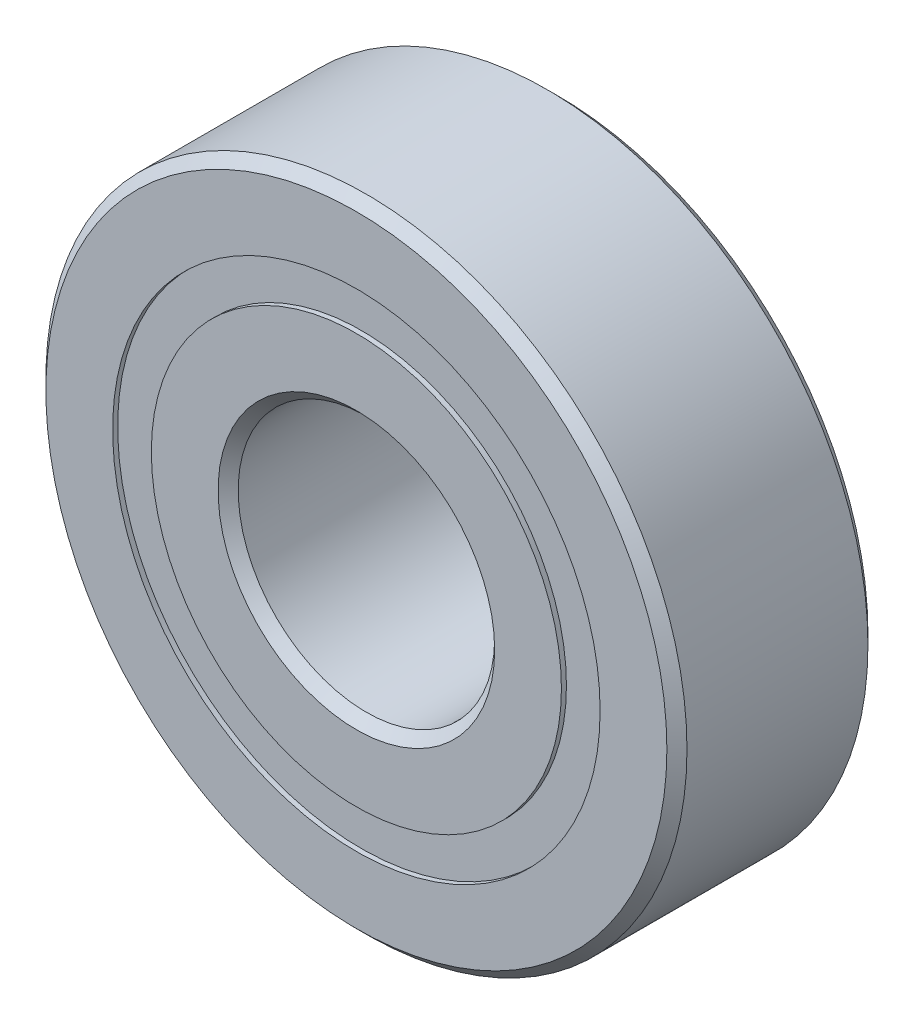
from build123d import *

# Parameters (mm, degrees)
CIRPATTERN1_COUNT = 10
SKETCH5_W         = 1.15919535
SKETCH5_H         = 0.957942858


with BuildPart() as part:
    # Sketch1 → Revolve1 (revolve)
    with BuildSketch(Plane(origin=(0, 0, 0), x_dir=(0, 0, -1), z_dir=(1, 0, 0))):
        with BuildLine():
            Line((2.24028, 7.9375), (-2.24028, 7.9375))
            Line((-2.24028, 7.9375), (-2.4892, 7.68858))
            Line((-2.4892, 7.68858), (-2.4892, 6.035221429))
            Line((-2.4892, 6.035221429), (-1.106311111, 6.035221429))
            ThreePointArc((-1.106311111, 6.035221429), (0, 6.76179465), (1.106311111, 6.035221429))
            Line((1.106311111, 6.035221429), (2.4892, 6.035221429))
            Line((2.4892, 6.035221429), (2.4892, 7.68858))
            Line((2.4892, 7.68858), (2.24028, 7.9375))
        make_face()
    revolve(axis=Axis((0, 0, 2.4892), (0, 0, -1)))


with BuildPart() as body_2:
    # Sketch3 → Revolve3 (revolve)
    with BuildSketch(Plane(origin=(0, 0, 0), x_dir=(0, 0, -1), z_dir=(1, 0, 0))):
        with BuildLine():
            Line((-2.4892, 5.077278571), (-1.106311111, 5.077278571))
            ThreePointArc((-1.106311111, 5.077278571), (0, 4.35070535), (1.106311111, 5.077278571))
            Line((1.106311111, 5.077278571), (2.4892, 5.077278571))
            Line((2.4892, 5.077278571), (2.4892, 3.42392))
            Line((2.4892, 3.42392), (2.24028, 3.175))
            Line((2.24028, 3.175), (-2.24028, 3.175))
            Line((-2.24028, 3.175), (-2.4892, 3.42392))
            Line((-2.4892, 3.42392), (-2.4892, 5.077278571))
        make_face()
    revolve(axis=Axis((0, 0, 2.4892), (0, 0, -1)))


with BuildPart() as body_3:
    # Sketch4 → Revolve4 (revolve)
    with BuildSketch(Plane(origin=(0, 0, 0), x_dir=(0, 0, -1), z_dir=(1, 0, 0))):
        with BuildLine():
            Line((-1.20554465, 5.55625), (1.20554465, 5.55625))
            ThreePointArc((1.20554465, 5.55625), (0, 6.76179465), (-1.20554465, 5.55625))
        make_face()
    revolve(axis=Axis((0, 5.55625, 1.20554465), (0, 0, -1)))


with BuildPart() as cirpattern1_1:
    # CirPattern1: pattern copy
    add(body_3.part.rotate(Axis((0, 0, -2.4892), (0, 0, 1)), 1 * 360 / CIRPATTERN1_COUNT))


with BuildPart() as cirpattern1_2:
    # CirPattern1: pattern copy
    add(body_3.part.rotate(Axis((0, 0, -2.4892), (0, 0, 1)), 2 * 360 / CIRPATTERN1_COUNT))


with BuildPart() as cirpattern1_3:
    # CirPattern1: pattern copy
    add(body_3.part.rotate(Axis((0, 0, -2.4892), (0, 0, 1)), 3 * 360 / CIRPATTERN1_COUNT))


with BuildPart() as cirpattern1_4:
    # CirPattern1: pattern copy
    add(body_3.part.rotate(Axis((0, 0, -2.4892), (0, 0, 1)), 4 * 360 / CIRPATTERN1_COUNT))


with BuildPart() as cirpattern1_5:
    # CirPattern1: pattern copy
    add(body_3.part.rotate(Axis((0, 0, -2.4892), (0, 0, 1)), 5 * 360 / CIRPATTERN1_COUNT))


with BuildPart() as cirpattern1_6:
    # CirPattern1: pattern copy
    add(body_3.part.rotate(Axis((0, 0, -2.4892), (0, 0, 1)), 6 * 360 / CIRPATTERN1_COUNT))


with BuildPart() as cirpattern1_7:
    # CirPattern1: pattern copy
    add(body_3.part.rotate(Axis((0, 0, -2.4892), (0, 0, 1)), 7 * 360 / CIRPATTERN1_COUNT))


with BuildPart() as cirpattern1_8:
    # CirPattern1: pattern copy
    add(body_3.part.rotate(Axis((0, 0, -2.4892), (0, 0, 1)), 8 * 360 / CIRPATTERN1_COUNT))


with BuildPart() as cirpattern1_9:
    # CirPattern1: pattern copy
    add(body_3.part.rotate(Axis((0, 0, -2.4892), (0, 0, 1)), 9 * 360 / CIRPATTERN1_COUNT))


with BuildPart() as body_13:
    # Sketch5 → Revolve5 (revolve)
    with BuildSketch(Plane(origin=(0, 0, 0), x_dir=(0, 0, -1), z_dir=(1, 0, 0))):
        with Locations((-1.785142325, 5.55625)):
            Rectangle(SKETCH5_W, SKETCH5_H)
        with Locations((1.785142325, 5.55625)):
            Rectangle(SKETCH5_W, SKETCH5_H)
    revolve(axis=Axis((0, 0, 2.4892), (0, 0, -1)))


solid = Compound([part.part, body_2.part, body_3.part, cirpattern1_1.part, cirpattern1_2.part, cirpattern1_3.part, cirpattern1_4.part, cirpattern1_5.part, cirpattern1_6.part, cirpattern1_7.part, cirpattern1_8.part, cirpattern1_9.part, body_13.part])
